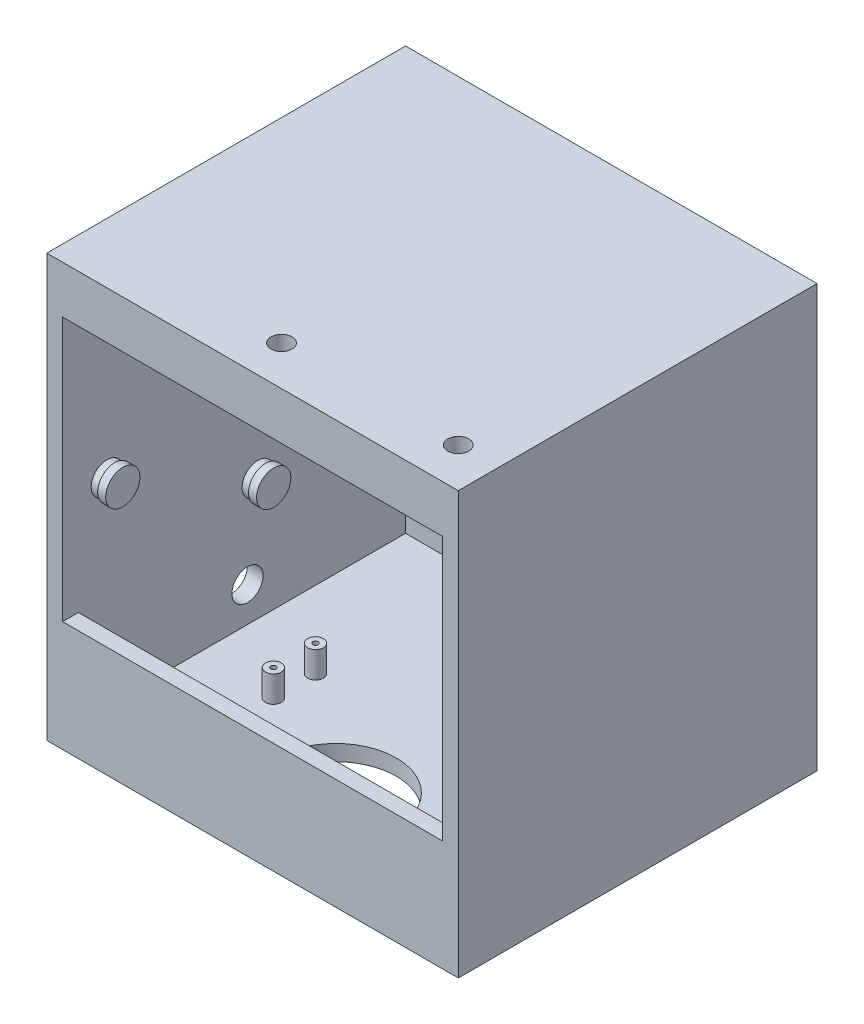
from build123d import *

# Parameters (mm, degrees)
BASE_PLATE_SKETCH_R   = 9.5
BASE_PLATE_SKETCH_R_2 = 3.175
BOSS_EXTRUDE2_DEPTH   = 31.75
BOSS_EXTRUDE2_2_DEPTH = 31.75
BOSS_EXTRUDE2_3_DEPTH = 31.75
BOSS_EXTRUDE2_4_DEPTH = 31.75
SKETCH1_5_W           = 495.3
SKETCH1_5_H           = 431.8
BOSS_EXTRUDE3_DEPTH   = 19.05
SKETCH1_6_R           = 73.025
SKETCH1_6_R_2         = 4.1
SKETCH1_6_R_3         = 4.7625
CUT_EXTRUDE1_DEPTH    = 99.05
SKETCH1_7_W           = 495.3
SKETCH1_7_H           = 431.8
SKETCH1_7_W_2         = 457.2
SKETCH1_7_H_2         = 393.7
BOSS_EXTRUDE4_DEPTH   = 469.9
BACK_WALL_SKETCH_W    = 457.2
BACK_WALL_SKETCH_H    = 152.4
BOSS_EXTRUDE5_DEPTH   = 38.3
BACK_WALL_SKETCH_5_W  = 457.2
BACK_WALL_SKETCH_5_H  = 152.4
CUT_EXTRUDE2_DEPTH    = 19.25
BACK_WALL_SKETCH_7_R  = 16.8
CUT_EXTRUDE5_DEPTH    = 28.875
BACK_WALL_SKETCH_8_R  = 1.875
CUT_EXTRUDE6_DEPTH    = 28.875
LEFT_WALL_SKETCH_R    = 18.75
CUT_EXTRUDE7_DEPTH    = 28.875
LEFT_WALL_SKETCH_3_R  = 19
BOSS_EXTRUDE6_DEPTH   = 9.349994
SKETCH5_R             = 20.6
BOSS_EXTRUDE7_DEPTH   = 9.7
CHAMBER_DOOR_SKETCH_W = 457.2
CHAMBER_DOOR_SKETCH_H = 317.5
CUT_EXTRUDE8_DEPTH    = 25.4
TOP_SKETCH_W          = 495.3
TOP_SKETCH_H          = 431.8
BOSS_EXTRUDE8_DEPTH   = 19.05
BOSS_EXTRUDE9_DEPTH   = 12.7
CUT_EXTRUDE9_REACH    = 510
SKETCH8_R             = 12.7
CUT_EXTRUDE10_REACH   = 21.05
SKETCH9_R             = 12.7


with BuildPart() as part:
    # Base Plate Sketch → Boss-Extrude2 (new body)
    with BuildSketch(Plane(origin=(0, 0, 0), x_dir=(1, 0, 0), z_dir=(0, 1, 0))):
        with Locations((-84.82915121, 32.220033819)):
            Circle(BASE_PLATE_SKETCH_R)
        with Locations((-84.82915121, 32.220033819)):
            Circle(BASE_PLATE_SKETCH_R_2, mode=Mode.SUBTRACT)
    extrude(amount=BOSS_EXTRUDE2_DEPTH)



with BuildPart() as body_2:
    # Base Plate Sketch → Boss-Extrude2 2 (new body)
    with BuildSketch(Plane(origin=(0, 0, 0), x_dir=(1, 0, 0), z_dir=(0, 1, 0))):
        with Locations((-84.82915121, -18.529928181)):
            Circle(BASE_PLATE_SKETCH_R)
        with Locations((-84.82915121, -18.529928181)):
            Circle(BASE_PLATE_SKETCH_R_2, mode=Mode.SUBTRACT)
    extrude(amount=BOSS_EXTRUDE2_2_DEPTH)


with BuildPart() as body_3:
    # Base Plate Sketch → Boss-Extrude2 3 (new body)
    with BuildSketch(Plane(origin=(0, 0, 0), x_dir=(1, 0, 0), z_dir=(0, 1, 0))):
        with Locations((188.22084879, -18.529928181)):
            Circle(BASE_PLATE_SKETCH_R)
        with Locations((188.22084879, -18.529928181)):
            Circle(BASE_PLATE_SKETCH_R_2, mode=Mode.SUBTRACT)
    extrude(amount=BOSS_EXTRUDE2_3_DEPTH)


with BuildPart() as body_4:
    # Base Plate Sketch → Boss-Extrude2 4 (new body)
    with BuildSketch(Plane(origin=(0, 0, 0), x_dir=(1, 0, 0), z_dir=(0, 1, 0))):
        with Locations((188.22084879, 32.220033819)):
            Circle(BASE_PLATE_SKETCH_R)
        with Locations((188.22084879, 32.220033819)):
            Circle(BASE_PLATE_SKETCH_R_2, mode=Mode.SUBTRACT)
    extrude(amount=BOSS_EXTRUDE2_4_DEPTH)


with BuildPart() as part_1:
    add(part.part)

    add(body_2.part)  # Boss-Extrude3 merges body 2

    add(body_3.part)  # Boss-Extrude3 merges body 3

    add(body_4.part)  # Boss-Extrude3 merges body 4
    # Sketch1_5 → Boss-Extrude3 (add)
    with BuildSketch(Plane(origin=(0, 0, 0), x_dir=(1, 0, 0), z_dir=(0, 1, 0))):
        with Locations((51.69584879, 35.795033019)):
            Rectangle(SKETCH1_5_W, SKETCH1_5_H)
    extrude(amount=-BOSS_EXTRUDE3_DEPTH)

    # Sketch1_6 → Cut-Extrude1 (cut)
    with BuildSketch(Plane(origin=(0, 0, 0), x_dir=(1, 0, 0), z_dir=(0, 1, 0))):
        with Locations((51.69584879, -80.092466981)):
            Circle(SKETCH1_6_R)
        with Locations((-72.12915121, -82.029928181)):
            Circle(SKETCH1_6_R_2)
        with Locations((-72.12915121, 203.670033819)):
            Circle(SKETCH1_6_R_3)
        with Locations((175.52084879, -82.029928181)):
            Circle(SKETCH1_6_R_2)
        with Locations((175.52084879, 203.670033819)):
            Circle(SKETCH1_6_R_3)
    extrude(amount=-CUT_EXTRUDE1_DEPTH, mode=Mode.SUBTRACT)

    # Sketch1_7 → Boss-Extrude4 (add)
    with BuildSketch(Plane(origin=(0, 0, 0), x_dir=(1, 0, 0), z_dir=(0, 1, 0))):
        with Locations((51.69584879, 35.795033019)):
            Rectangle(SKETCH1_7_W, SKETCH1_7_H)
        with Locations((51.69584879, 35.795033019)):
            Rectangle(SKETCH1_7_W_2, SKETCH1_7_H_2, mode=Mode.SUBTRACT)
    extrude(amount=BOSS_EXTRUDE4_DEPTH)

    # Back Wall Sketch → Boss-Extrude5 (add)
    with BuildSketch(Plane.XY.offset(-232.645033019)):
        with Locations((51.69584879, 190.5)):
            Rectangle(BACK_WALL_SKETCH_W, BACK_WALL_SKETCH_H)
    extrude(amount=-BOSS_EXTRUDE5_DEPTH)

    # Back Wall Sketch_5 → Cut-Extrude2 (cut)
    with BuildSketch(Plane.XY.offset(-232.645033019)):
        with Locations((51.69584879, 190.5)):
            Rectangle(BACK_WALL_SKETCH_5_W, BACK_WALL_SKETCH_5_H)
    extrude(amount=-CUT_EXTRUDE2_DEPTH, mode=Mode.SUBTRACT)

    # Back Wall Sketch_7 → Cut-Extrude5 (cut)
    with BuildSketch(Plane.XY.offset(-232.645033019)):
        with Locations((184.12128879, 148.2999955)):
            Circle(BACK_WALL_SKETCH_7_R)
    extrude(amount=-CUT_EXTRUDE5_DEPTH, mode=Mode.SUBTRACT)

    # Back Wall Sketch_8 → Cut-Extrude6 (cut)
    with BuildSketch(Plane.XY.offset(-232.645033019)):
        with Locations((-117.971635681, 342.32499988)):
            Circle(BACK_WALL_SKETCH_8_R)
        with Locations((-21.04165115, 294.98749994)):
            Circle(BACK_WALL_SKETCH_8_R)
        with Locations((-117.971635681, 316.57499988)):
            Circle(BACK_WALL_SKETCH_8_R)
        with Locations((124.43334873, 294.98749994)):
            Circle(BACK_WALL_SKETCH_8_R)
        with Locations((221.363333262, 342.32499988)):
            Circle(BACK_WALL_SKETCH_8_R)
        with Locations((221.363333262, 316.57499988)):
            Circle(BACK_WALL_SKETCH_8_R)
    extrude(amount=-CUT_EXTRUDE6_DEPTH, mode=Mode.SUBTRACT)

    # Left Wall Sketch → Cut-Extrude7 (cut)
    with BuildSketch(Plane(origin=(-176.90415121, 0, 0), x_dir=(0, 0, -1), z_dir=(1, 0, 0))):
        with Locations((42.445032419, 41.6100006)):
            Circle(LEFT_WALL_SKETCH_R)
    extrude(amount=-CUT_EXTRUDE7_DEPTH, mode=Mode.SUBTRACT)

    # Left Wall Sketch_3 → Boss-Extrude6 (add)
    with BuildSketch(Plane(origin=(-176.90415121, 0, 0), x_dir=(0, 0, -1), z_dir=(1, 0, 0))):
        with Locations((-126.714166981, 237.439962)):
            Circle(LEFT_WALL_SKETCH_3_R)
        with Locations((54.895071019, 145.999962)):
            Circle(LEFT_WALL_SKETCH_3_R)
    extrude(amount=BOSS_EXTRUDE6_DEPTH)

    # Sketch5 → Boss-Extrude7 (add)
    with BuildSketch(Plane(origin=(-167.55415721, 0, 0), x_dir=(0, 0, -1), z_dir=(1, 0, 0))):
        with Locations((-126.714166981, 237.439962)):
            Circle(SKETCH5_R)
        with Locations((54.895071019, 145.999962)):
            Circle(SKETCH5_R)
    extrude(amount=BOSS_EXTRUDE7_DEPTH)

    # Chamber Door Sketch → Cut-Extrude8 (cut)
    with BuildSketch(Plane(origin=(0, 0, 161.054966981), x_dir=(-1, 0, 0), z_dir=(0, 0, -1))):
        with Locations((-51.69584879, 273.05)):
            Rectangle(CHAMBER_DOOR_SKETCH_W, CHAMBER_DOOR_SKETCH_H)
    extrude(amount=-CUT_EXTRUDE8_DEPTH, mode=Mode.SUBTRACT)

    # Top Sketch → Boss-Extrude8 (add)
    with BuildSketch(Plane(origin=(0, 469.9, 0), x_dir=(1, 0, 0), z_dir=(0, 1, 0))):
        with Locations((51.69584879, 35.795033019)):
            Rectangle(TOP_SKETCH_W, TOP_SKETCH_H)
    extrude(amount=BOSS_EXTRUDE8_DEPTH)

    # Sketch7 → Boss-Extrude9 (add)
    with BuildSketch(Plane.XZ.offset(-469.9)):
        Polygon((22.020139267, -181.825033019), (11.010069633, -162.755033019), (-11.010069633, -162.755033019), (-22.020139267, -181.825033019), (-11.010069633, -200.895033019), (11.010069633, -200.895033019), align=None)
    extrude(amount=BOSS_EXTRUDE9_DEPTH)

    # Sketch8 → Cut-Extrude9 (cut, up to next)
    with BuildSketch(Plane(origin=(0, 488.95, 0), x_dir=(1, 0, 0), z_dir=(0, 1, 0)), mode=Mode.PRIVATE) as cut_extrude9_sk1:
        with Locations((38.99584879, -132.479966981)):
            Circle(SKETCH8_R)
    cut_extrude9_tool1 = extrude(cut_extrude9_sk1.sketch, amount=-CUT_EXTRUDE9_REACH, mode=Mode.PRIVATE) & part_1.part
    add(cut_extrude9_tool1.solids().sort_by_distance((38.995849, 488.95, 132.479967))[0], mode=Mode.SUBTRACT)
    # Sketch8 → Cut-Extrude9 (cut, up to next)
    with BuildSketch(Plane(origin=(0, 488.95, 0), x_dir=(1, 0, 0), z_dir=(0, 1, 0)), mode=Mode.PRIVATE) as cut_extrude9_sk2:
        with Locations((251.72084879, -132.479966981)):
            Circle(SKETCH8_R)
    cut_extrude9_tool2 = extrude(cut_extrude9_sk2.sketch, amount=-CUT_EXTRUDE9_REACH, mode=Mode.PRIVATE) & part_1.part
    add(cut_extrude9_tool2.solids().sort_by_distance((251.720849, 488.95, 132.479967))[0], mode=Mode.SUBTRACT)

    # Sketch9 → Cut-Extrude10 (cut, up to next)
    with BuildSketch(Plane(origin=(-176.90415121, 0, 0), x_dir=(0, 0, -1), z_dir=(1, 0, 0)), mode=Mode.PRIVATE) as cut_extrude10_sk1:
        with Locations((170.145033019, 102)):
            Circle(SKETCH9_R)
    cut_extrude10_tool1 = extrude(cut_extrude10_sk1.sketch, amount=-CUT_EXTRUDE10_REACH, mode=Mode.PRIVATE) & part_1.part
    add(cut_extrude10_tool1.solids().sort_by_distance((-176.904151, 102, -170.145033))[0], mode=Mode.SUBTRACT)


solid = part_1.part
